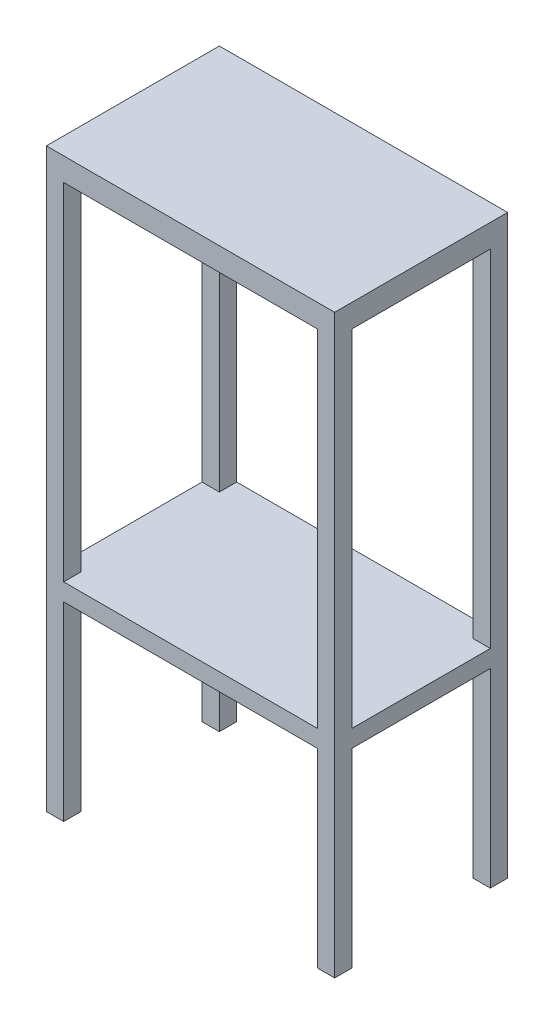
from build123d import *

# Parameters (mm, degrees)
SKETCH1_W               = 500
SKETCH1_H               = 300
BOSS_EXTRUDE1_DEPTH     = 1000
SKETCH2_W               = 440
SKETCH2_H               = 600
CUT_EXTRUDE1_DEPTH      = 1000
CUT_EXTRUDE1_DEPTH_BACK = 1000
SKETCH3_W               = 440
SKETCH3_H               = 330
CUT_EXTRUDE2_DEPTH      = 1000
CUT_EXTRUDE2_DEPTH_BACK = 1000
SKETCH4_W               = 240
SKETCH4_H               = 600
CUT_EXTRUDE3_DEPTH      = 1000
CUT_EXTRUDE3_DEPTH_BACK = 1000
SKETCH5_W               = 240
SKETCH5_H               = 330
CUT_EXTRUDE4_DEPTH      = 1000
CUT_EXTRUDE4_DEPTH_BACK = 1000


with BuildPart() as part:
    # Sketch1 → Boss-Extrude1 (new body)
    with BuildSketch(Plane(origin=(0, 0, 0), x_dir=(1, 0, 0), z_dir=(0, 1, 0))):
        Rectangle(SKETCH1_W, SKETCH1_H)
    extrude(amount=BOSS_EXTRUDE1_DEPTH)

    # Sketch2 → Cut-Extrude1 (cut, two sides)
    with BuildSketch(Plane.XY) as cut_extrude1_sk:
        with Locations((0, 660)):
            Rectangle(SKETCH2_W, SKETCH2_H)
    extrude(amount=CUT_EXTRUDE1_DEPTH, mode=Mode.SUBTRACT)
    extrude(cut_extrude1_sk.sketch, amount=-CUT_EXTRUDE1_DEPTH_BACK, mode=Mode.SUBTRACT)

    # Sketch3 → Cut-Extrude2 (cut, two sides)
    with BuildSketch(Plane.XY) as cut_extrude2_sk:
        with Locations((0, 165)):
            Rectangle(SKETCH3_W, SKETCH3_H)
    extrude(amount=CUT_EXTRUDE2_DEPTH, mode=Mode.SUBTRACT)
    extrude(cut_extrude2_sk.sketch, amount=-CUT_EXTRUDE2_DEPTH_BACK, mode=Mode.SUBTRACT)

    # Sketch4 → Cut-Extrude3 (cut, two sides)
    with BuildSketch(Plane(origin=(0, 0, 0), x_dir=(0, 0, -1), z_dir=(1, 0, 0))) as cut_extrude3_sk:
        with Locations((0, 660)):
            Rectangle(SKETCH4_W, SKETCH4_H)
    extrude(amount=CUT_EXTRUDE3_DEPTH, mode=Mode.SUBTRACT)
    extrude(cut_extrude3_sk.sketch, amount=-CUT_EXTRUDE3_DEPTH_BACK, mode=Mode.SUBTRACT)

    # Sketch5 → Cut-Extrude4 (cut, two sides)
    with BuildSketch(Plane(origin=(0, 0, 0), x_dir=(0, 0, -1), z_dir=(1, 0, 0))) as cut_extrude4_sk:
        with Locations((0, 165)):
            Rectangle(SKETCH5_W, SKETCH5_H)
    extrude(amount=CUT_EXTRUDE4_DEPTH, mode=Mode.SUBTRACT)
    extrude(cut_extrude4_sk.sketch, amount=-CUT_EXTRUDE4_DEPTH_BACK, mode=Mode.SUBTRACT)


solid = part.part
